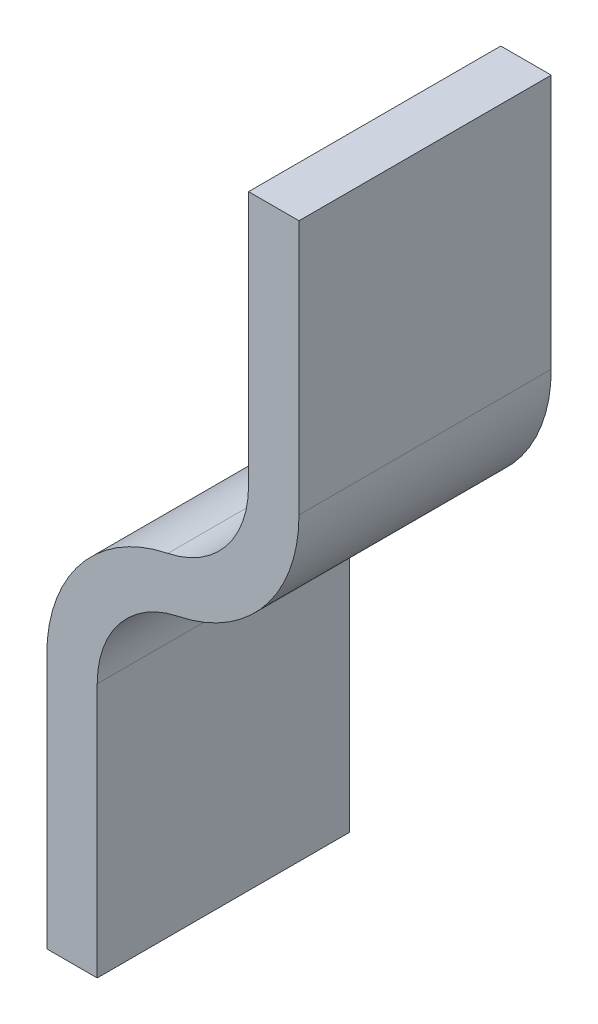
from build123d import *

# Parameters (mm, degrees)
BOSS_EXTRUDE2_DEPTH = 10


with BuildPart() as part:
    # Sketch1 → Boss-Extrude2 (new body)
    with BuildSketch(Plane.XY):
        with BuildLine():
            Line((0, 0), (2, 0))
            Line((2, 0), (2, -10.101020514))
            ThreePointArc((2, -10.101020514), (0.647580015, -13.895753707), (-2.8, -15.979795897))
            ThreePointArc((-2.8, -15.979795897), (-5.098386677, -17.369157357), (-6, -19.898979486))
            Line((-6, -19.898979486), (-6, -30))
            Line((-6, -30), (-8, -30))
            Line((-8, -30), (-8, -19.898979486))
            ThreePointArc((-8, -19.898979486), (-6.647580015, -16.104246293), (-3.2, -14.020204103))
            ThreePointArc((-3.2, -14.020204103), (-0.901613323, -12.630842643), (0, -10.101020514))
            Line((0, -10.101020514), (0, 0))
        make_face()
    extrude(amount=-BOSS_EXTRUDE2_DEPTH)


solid = part.part
